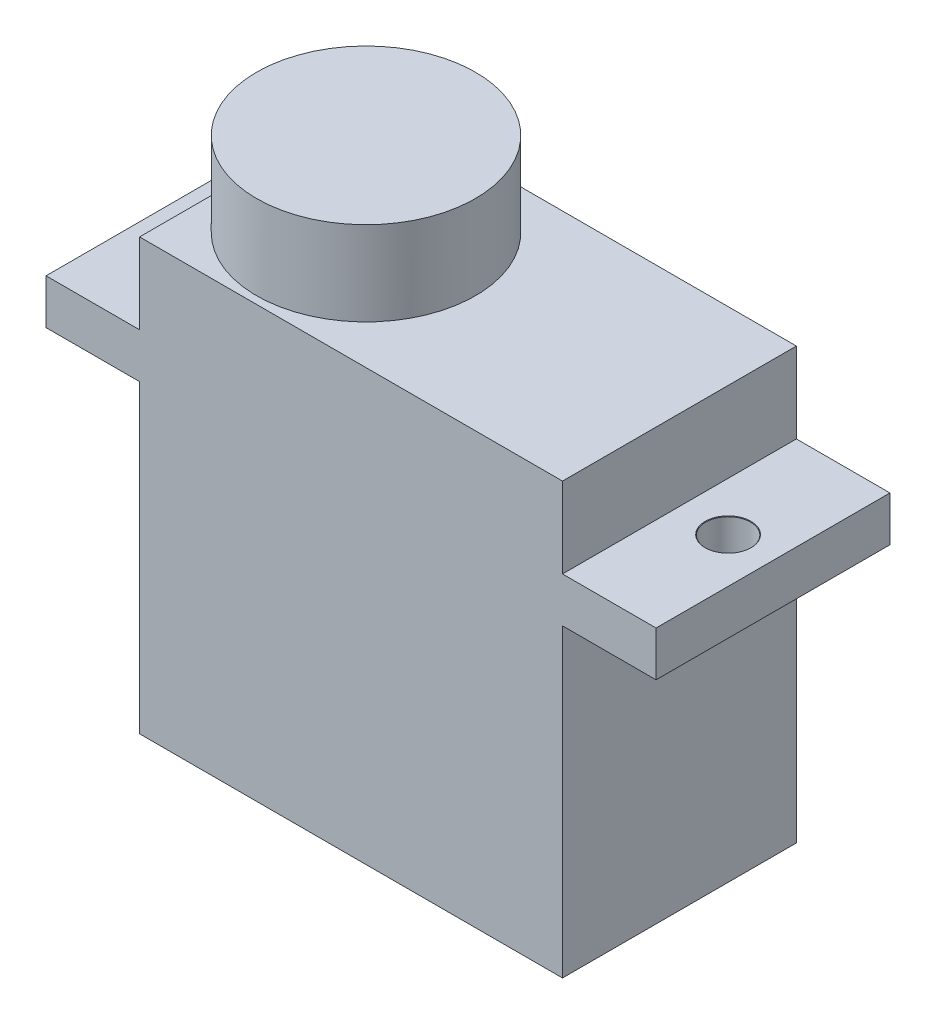
from build123d import *

# Parameters (mm, degrees)
SKETCH1_W                      = 22.6
SKETCH1_H                      = 12.5
BOSS_EXTRUDE1_DEPTH            = 23
SKETCH2_W                      = 5
SKETCH2_H                      = 12.5
BOSS_EXTRUDE2_DEPTH            = 2.4
M2_CLEARANCE_HOLE1_D           = 2.4
M2_CLEARANCE_HOLE1_DEPTH       = 21.51
M2_CLEARANCE_HOLE1_CSINK_D     = 2.45
M2_CLEARANCE_HOLE1_CSINK_ANGLE = 90
M2_CLEARANCE_HOLE1_TIP         = 0.721032743
SKETCH5_R                      = 5.85
BOSS_EXTRUDE3_DEPTH            = 4.5


with BuildPart() as part:
    # Sketch1 → Boss-Extrude1 (new body)
    with BuildSketch(Plane(origin=(0, 0, 0), x_dir=(1, 0, 0), z_dir=(0, 1, 0))):
        Rectangle(SKETCH1_W, SKETCH1_H)
    extrude(amount=BOSS_EXTRUDE1_DEPTH)

    # Sketch2 → Boss-Extrude2 (add)
    with BuildSketch(Plane(origin=(0, 18.7, 0), x_dir=(1, 0, 0), z_dir=(0, 1, 0))):
        with Locations((13.8, 0)):
            Rectangle(SKETCH2_W, SKETCH2_H)
        with Locations((-13.8, 0)):
            Rectangle(SKETCH2_W, SKETCH2_H)
    extrude(amount=-BOSS_EXTRUDE2_DEPTH)

    # M2 Clearance Hole1
    with Locations(Plane(origin=(0, 18.7, 0), x_dir=(1, 0, 0), z_dir=(0, 1, 0))):
        with Locations((-13.9, 0), (13.9, 0)):
            CounterSinkHole(M2_CLEARANCE_HOLE1_D / 2, M2_CLEARANCE_HOLE1_CSINK_D / 2, depth=M2_CLEARANCE_HOLE1_DEPTH, counter_sink_angle=M2_CLEARANCE_HOLE1_CSINK_ANGLE)
            with Locations((0, 0, -(M2_CLEARANCE_HOLE1_DEPTH + M2_CLEARANCE_HOLE1_TIP / 2))):  # 118° drill point
                Cone(0, M2_CLEARANCE_HOLE1_D / 2, M2_CLEARANCE_HOLE1_TIP, mode=Mode.SUBTRACT)

    # Sketch5 → Boss-Extrude3 (add)
    with BuildSketch(Plane(origin=(0, 23, 0), x_dir=(1, 0, 0), z_dir=(0, 1, 0))):
        with Locations((-5.45, 0)):
            Circle(SKETCH5_R)
    extrude(amount=BOSS_EXTRUDE3_DEPTH)


solid = part.part
